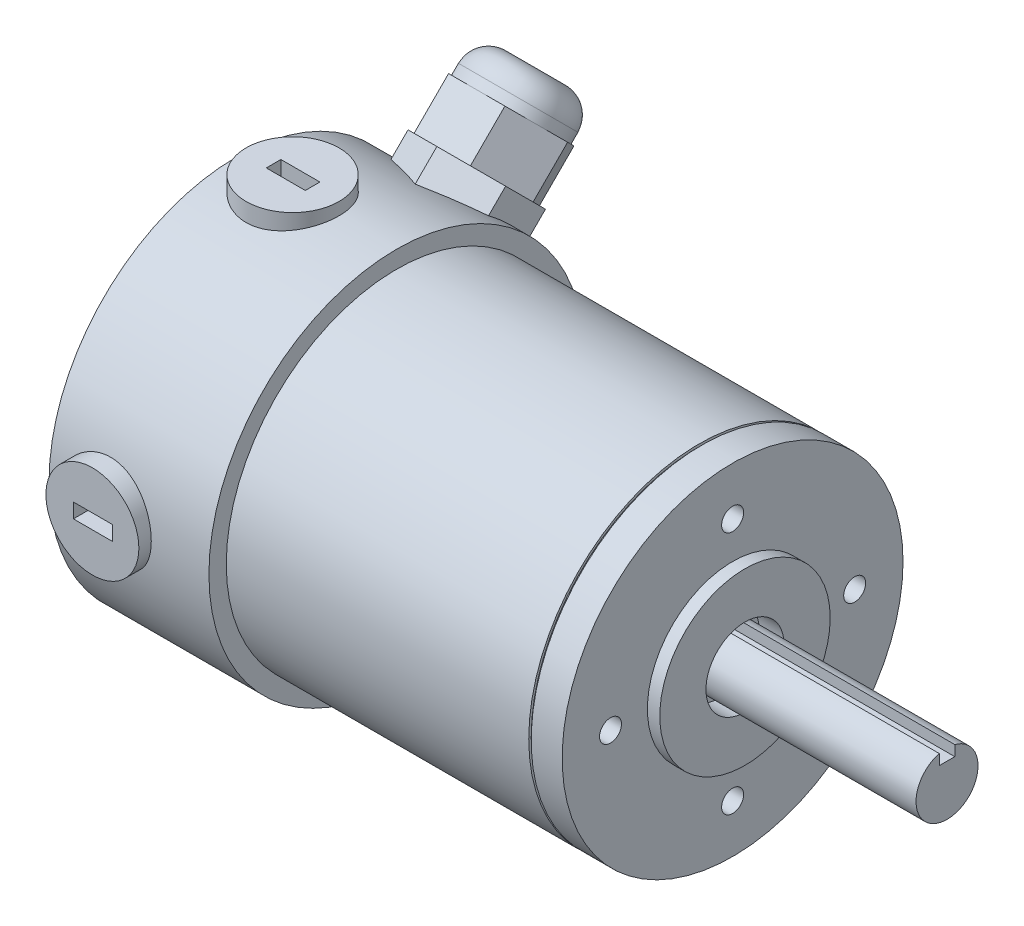
from build123d import *

# Parameters (mm, degrees)
SKETCH1_R            = 34.925
BASE_EXTRUDE_DEPTH   = 6.35
SKETCH2_R            = 34.425
BOSS_EXTRUDE3_DEPTH  = 0.5
SKETCH4_R            = 34.925
BOSS_EXTRUDE4_DEPTH  = 61.984
SKETCH5_R            = 17.4625
BOSS_EXTRUDE5_DEPTH  = 2.54
SKETCH6_R            = 8
CUT_EXTRUDE1_DEPTH   = 5.08
BOSS_EXTRUDE6_DEPTH  = 46.482
SKETCH8_R            = 38.481
BOSS_EXTRUDE7_DEPTH  = 32.766
SKETCH9_R            = 8
CUT_EXTRUDE2_DEPTH   = 2.54
SKETCH10_R           = 6.35
BOSS_EXTRUDE8_DEPTH  = 20.828
SKETCH11_R           = 9.525
BOSS_EXTRUDE9_DEPTH  = 41.021
SKETCH12_R           = 9.525
BOSS_EXTRUDE10_DEPTH = 41.021
SKETCH14_W           = 8
SKETCH14_H           = 3
CUT_EXTRUDE3_DEPTH   = 4
SKETCH15_W           = 8
SKETCH15_H           = 3
CUT_EXTRUDE4_DEPTH   = 4
SKETCH16_W           = 8
SKETCH16_H           = 3
CUT_EXTRUDE5_DEPTH   = 4
SKETCH17_W           = 8
SKETCH17_H           = 3
CUT_EXTRUDE6_DEPTH   = 4
SKETCH18_R           = 2.25
CUT_EXTRUDE7_DEPTH   = 12.7
BOSS_EXTRUDE12_DEPTH = 43
BOSS_EXTRUDE13_DEPTH = 10
SKETCH23_R           = 10
BOSS_EXTRUDE14_DEPTH = 7
FILLET1_R            = 5


with BuildPart() as part:
    # Sketch1 → Base-Extrude (new body)
    with BuildSketch(Plane(origin=(0, 0, 0), x_dir=(0, 0, -1), z_dir=(1, 0, 0))):
        Circle(SKETCH1_R)
    extrude(amount=-BASE_EXTRUDE_DEPTH)

    # Sketch2 → Boss-Extrude3 (add)
    with BuildSketch(Plane.ZY.offset(6.35)):
        Circle(SKETCH2_R)
    extrude(amount=BOSS_EXTRUDE3_DEPTH)

    # Sketch4 → Boss-Extrude4 (add)
    with BuildSketch(Plane.ZY.offset(6.85)):
        Circle(SKETCH4_R)
    extrude(amount=BOSS_EXTRUDE4_DEPTH)

    # Sketch5 → Boss-Extrude5 (add)
    with BuildSketch(Plane(origin=(0, 0, 0), x_dir=(0, 0, -1), z_dir=(1, 0, 0))):
        Circle(SKETCH5_R)
    extrude(amount=BOSS_EXTRUDE5_DEPTH)

    # Sketch6 → Cut-Extrude1 (cut)
    with BuildSketch(Plane(origin=(2.54, 0, 0), x_dir=(0, 0, -1), z_dir=(1, 0, 0))):
        Circle(SKETCH6_R)
    extrude(amount=-CUT_EXTRUDE1_DEPTH, mode=Mode.SUBTRACT)

    # Sketch7 → Boss-Extrude6 (add)
    with BuildSketch(Plane(origin=(-2.54, 0, 0), x_dir=(0, 0, -1), z_dir=(1, 0, 0))):
        with BuildLine():
            Line((-1.588, 6.148231941), (-1.588, 4))
            Line((-1.588, 4), (1.5875, 4))
            Line((1.5875, 4), (1.5875, 6.148361062))
            ThreePointArc((1.5875, 6.148361062), (0.000258202, -6.349999995), (-1.588, 6.148231941))
        make_face()
    extrude(amount=BOSS_EXTRUDE6_DEPTH)

    # Sketch8 → Boss-Extrude7 (add)
    with BuildSketch(Plane.ZY.offset(68.834)):
        Circle(SKETCH8_R)
    extrude(amount=BOSS_EXTRUDE7_DEPTH)

    # Sketch9 → Cut-Extrude2 (cut)
    with BuildSketch(Plane.ZY.offset(101.6)):
        Circle(SKETCH9_R)
    extrude(amount=-CUT_EXTRUDE2_DEPTH, mode=Mode.SUBTRACT)

    # Sketch10 → Boss-Extrude8 (add)
    with BuildSketch(Plane.ZY.offset(99.06)):
        Circle(SKETCH10_R)
    extrude(amount=BOSS_EXTRUDE8_DEPTH)

    # Sketch11 → Boss-Extrude9 (add, symmetric)
    with BuildSketch(Plane(origin=(0, 0, 0), x_dir=(1, 0, 0), z_dir=(0, 1, 0))):
        with Locations((-90.17, 0)):
            Circle(SKETCH11_R)
    extrude(amount=BOSS_EXTRUDE9_DEPTH, both=True)

    # Sketch12 → Boss-Extrude10 (add, symmetric)
    with BuildSketch(Plane.XY):
        with Locations((-90.17, 0)):
            Circle(SKETCH12_R)
    extrude(amount=BOSS_EXTRUDE10_DEPTH, both=True)

    # Sketch14 → Cut-Extrude3 (cut)
    with BuildSketch(Plane(origin=(0, 41.021, 0), x_dir=(-1, 0, 0), z_dir=(0, 1, 0))):
        with Locations((90.06265285, 0)):
            Rectangle(SKETCH14_W, SKETCH14_H)
    extrude(amount=-CUT_EXTRUDE3_DEPTH, mode=Mode.SUBTRACT)

    # Sketch15 → Cut-Extrude4 (cut)
    with BuildSketch(Plane.XZ.offset(41.021)):
        with Locations((-90.06265285, 0)):
            Rectangle(SKETCH15_W, SKETCH15_H)
    extrude(amount=-CUT_EXTRUDE4_DEPTH, mode=Mode.SUBTRACT)

    # Sketch16 → Cut-Extrude5 (cut)
    with BuildSketch(Plane.XY.offset(41.021)):
        with Locations((-90.06265285, 0)):
            Rectangle(SKETCH16_W, SKETCH16_H)
    extrude(amount=-CUT_EXTRUDE5_DEPTH, mode=Mode.SUBTRACT)

    # Sketch17 → Cut-Extrude6 (cut)
    with BuildSketch(Plane(origin=(0, 0, -41.021), x_dir=(-1, 0, 0), z_dir=(0, 0, -1))):
        with Locations((90.06265285, 0)):
            Rectangle(SKETCH17_W, SKETCH17_H)
    extrude(amount=-CUT_EXTRUDE6_DEPTH, mode=Mode.SUBTRACT)

    # Sketch18 → Cut-Extrude7 (cut)
    with BuildSketch(Plane(origin=(0, 0, 0), x_dir=(0, 0, -1), z_dir=(1, 0, 0))):
        with Locations((0, 25.019)):
            Circle(SKETCH18_R)
        with Locations((25.019, 0)):
            Circle(SKETCH18_R)
        with Locations((0, -25.019)):
            Circle(SKETCH18_R)
        with Locations((-25.019, 0)):
            Circle(SKETCH18_R)
    extrude(amount=-CUT_EXTRUDE7_DEPTH, mode=Mode.SUBTRACT)

    # Sketch21 → Boss-Extrude12 (add)
    with BuildSketch(Plane(origin=(0, 0, 0), x_dir=(-1, 0, 0), z_dir=(0, 0.707106781, -0.707106781))):
        Polygon((82.834, -11.547005384), (92.834, -5.773502692), (92.834, 5.773502692), (82.834, 11.547005384), (72.834, 5.773502692), (72.834, -5.773502692), align=None)
    extrude(amount=BOSS_EXTRUDE12_DEPTH)

    # Sketch22 → Boss-Extrude13 (add)
    with BuildSketch(Plane(origin=(0, 30.405591591, -30.405591591), x_dir=(-1, 0, 0), z_dir=(0, 0.707106781, -0.707106781))):
        Polygon((88.607502692, 10), (77.060497308, 10), (71.286994616, 0), (77.060497308, -10), (88.607502692, -10), (94.381005384, 0), align=None)
    extrude(amount=BOSS_EXTRUDE13_DEPTH)

    # Sketch23 → Boss-Extrude14 (add)
    with BuildSketch(Plane(origin=(0, 37.476659403, -37.476659403), x_dir=(-1, 0, 0), z_dir=(0, 0.707106781, -0.707106781))):
        with Locations((82.834, 0)):
            Circle(SKETCH23_R)
    extrude(amount=BOSS_EXTRUDE14_DEPTH)

    # Fillet1
    fillet1_edges = [part.edges().sort_by_distance(p)[0] for p in [
        (-72.834, 42.426406871, -42.426406871),
    ]]
    fillet(fillet1_edges, radius=FILLET1_R)


solid = part.part
